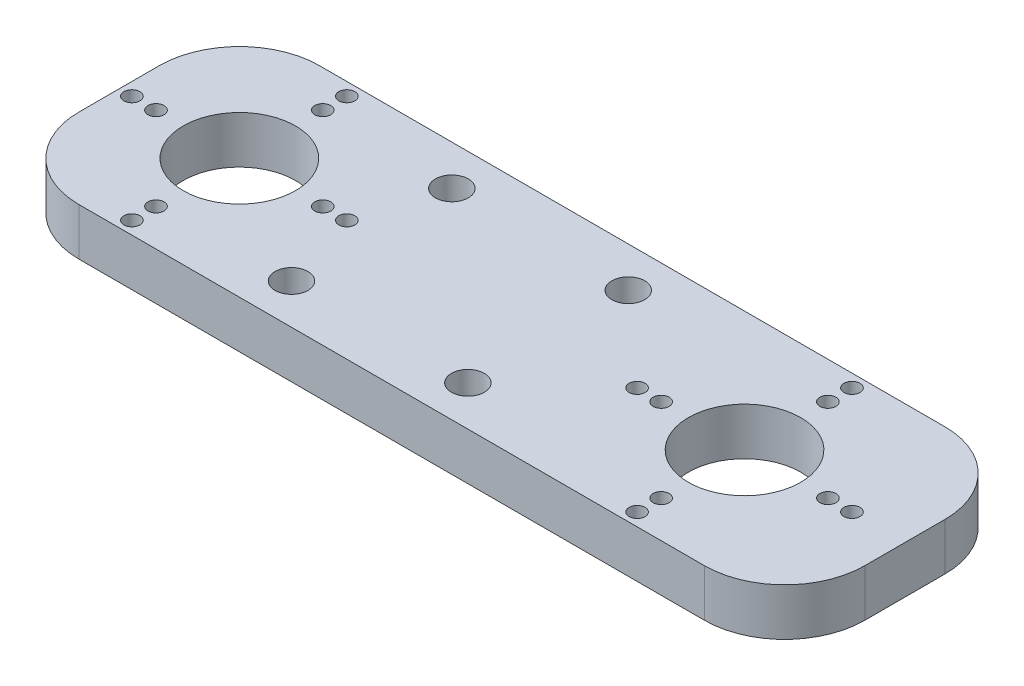
from build123d import *

# Parameters (mm, degrees)
SKETCH1_W           = 98
SKETCH1_H           = 30
SKETCH1_R           = 7
SKETCH1_R_2         = 1
BOSS_EXTRUDE1_DEPTH = 5.9
SKETCH4_R           = 7
SKETCH4_R_2         = 1
CUT_EXTRUDE3_DEPTH  = 10
FILLET1_R           = 10
SKETCH5_R           = 2.05
CUT_EXTRUDE4_DEPTH  = 10


with BuildPart() as part:
    # Sketch1 → Boss-Extrude1 (new body)
    with BuildSketch(Plane(origin=(0, 0, 0), x_dir=(1, 0, 0), z_dir=(0, 1, 0))):
        Rectangle(SKETCH1_W, SKETCH1_H)
        with Locations((-34, 0)):
            Circle(SKETCH1_R, mode=Mode.SUBTRACT)
        with Locations((-44.4, 0)):
            Circle(SKETCH1_R_2, mode=Mode.SUBTRACT)
        with Locations((-47.4, 0)):
            Circle(SKETCH1_R_2, mode=Mode.SUBTRACT)
        with Locations((-34, 10.4)):
            Circle(SKETCH1_R_2, mode=Mode.SUBTRACT)
        with Locations((-34, 13.4)):
            Circle(SKETCH1_R_2, mode=Mode.SUBTRACT)
        with Locations((-23.6, 0)):
            Circle(SKETCH1_R_2, mode=Mode.SUBTRACT)
        with Locations((-20.6, 0)):
            Circle(SKETCH1_R_2, mode=Mode.SUBTRACT)
        with Locations((-34, -10.4)):
            Circle(SKETCH1_R_2, mode=Mode.SUBTRACT)
        with Locations((-34, -13.4)):
            Circle(SKETCH1_R_2, mode=Mode.SUBTRACT)
    extrude(amount=BOSS_EXTRUDE1_DEPTH)

    # Sketch4 → Cut-Extrude3 (cut)
    with BuildSketch(Plane(origin=(0, 5.9, 0), x_dir=(1, 0, 0), z_dir=(0, 1, 0))):
        with Locations((-34, 0)):
            Circle(SKETCH4_R)
        with Locations((-34, -13.4)):
            Circle(SKETCH4_R_2)
        with Locations((-34, -10.4)):
            Circle(SKETCH4_R_2)
        with Locations((-44.4, 0)):
            Circle(SKETCH4_R_2)
        with Locations((-47.4, 0)):
            Circle(SKETCH4_R_2)
        with Locations((-34, 13.4)):
            Circle(SKETCH4_R_2)
        with Locations((-23.6, 0)):
            Circle(SKETCH4_R_2)
        with Locations((-20.6, 0)):
            Circle(SKETCH4_R_2)
        with Locations((-34, 10.4)):
            Circle(SKETCH4_R_2)
        with Locations((29, -13.4)):
            Circle(SKETCH4_R_2)
        with Locations((29, -10.4)):
            Circle(SKETCH4_R_2)
        with Locations((42.4, 0)):
            Circle(SKETCH4_R_2)
        with Locations((39.4, 0)):
            Circle(SKETCH4_R_2)
        with Locations((29, 0)):
            Circle(SKETCH4_R)
        with Locations((29, 10.4)):
            Circle(SKETCH4_R_2)
        with Locations((29, 13.4)):
            Circle(SKETCH4_R_2)
        with Locations((18.6, 0)):
            Circle(SKETCH4_R_2)
        with Locations((15.6, 0)):
            Circle(SKETCH4_R_2)
    extrude(amount=-CUT_EXTRUDE3_DEPTH, mode=Mode.SUBTRACT)

    # Fillet1
    fillet1_edges = [part.edges().sort_by_distance(p)[0] for p in [
        (49, 2.95, 15),
        (-49, 2.95, 15),
        (-49, 2.95, -15),
        (49, 2.95, -15),
    ]]
    fillet(fillet1_edges, radius=FILLET1_R)

    # Sketch5 → Cut-Extrude4 (cut)
    with BuildSketch(Plane(origin=(0, 5.9, 0), x_dir=(1, 0, 0), z_dir=(0, 1, 0))):
        with Locations((-17.5, 10)):
            Circle(SKETCH5_R)
        with Locations((-17.5, -10)):
            Circle(SKETCH5_R)
        with Locations((4.5, -10)):
            Circle(SKETCH5_R)
        with Locations((4.5, 10)):
            Circle(SKETCH5_R)
    extrude(amount=-CUT_EXTRUDE4_DEPTH, mode=Mode.SUBTRACT)


solid = part.part
